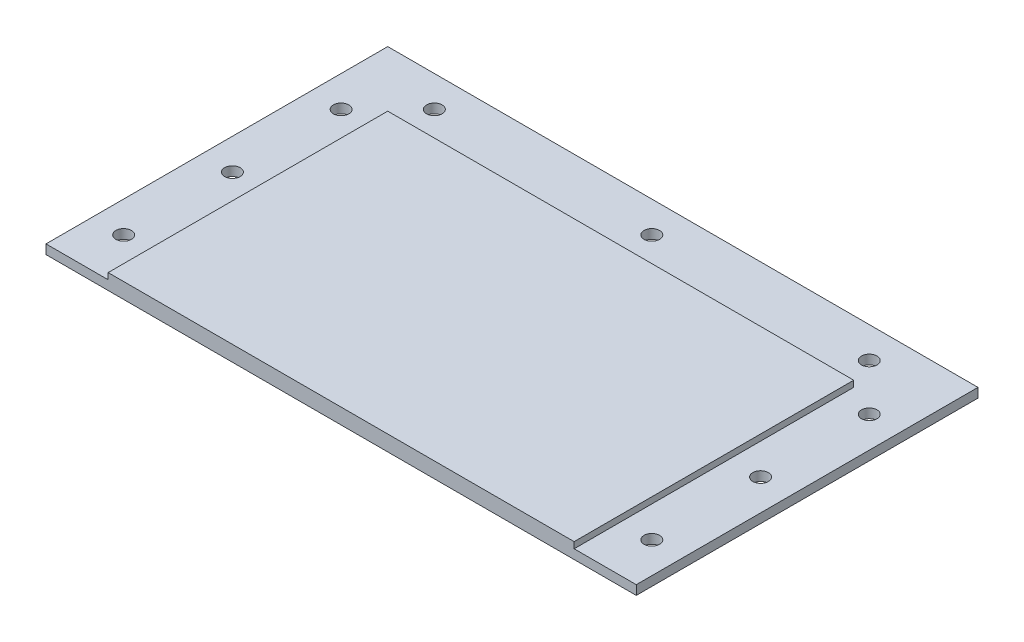
from build123d import *

# Parameters (mm, degrees)
CROQUIS1_W              = 150
CROQUIS1_H              = 90
SALIENTE_EXTRUIR1_DEPTH = 5
SALIENTE_EXTRUIR2_DEPTH = 3
CROQUIS2_R              = 2.5
CORTAR_EXTRUIR1_DEPTH   = 10


with BuildPart() as part:
    # Croquis1 → Saliente-Extruir1 (new body)
    with BuildSketch(Plane(origin=(0, 0, 0), x_dir=(1, 0, 0), z_dir=(0, 1, 0))):
        Rectangle(CROQUIS1_W, CROQUIS1_H)
    extrude(amount=SALIENTE_EXTRUIR1_DEPTH)

    # Croquis1_3 → Saliente-Extruir2 (add)
    with BuildSketch(Plane(origin=(0, 0, 0), x_dir=(1, 0, 0), z_dir=(0, 1, 0))):
        Polygon((-75, -45), (-75, 45), (75, 45), (75, -45), (95, -45), (95, 65), (-95, 65), (-95, -45), align=None)
    extrude(amount=SALIENTE_EXTRUIR2_DEPTH)

    # Croquis2 → Cortar-Extruir1 (cut)
    with BuildSketch(Plane.XZ):
        with Locations((85, 30)):
            Circle(CROQUIS2_R)
        with Locations((70, -55)):
            Circle(CROQUIS2_R)
        with Locations((-85, -40)):
            Circle(CROQUIS2_R)
        with Locations((-85, -5)):
            Circle(CROQUIS2_R)
        with Locations((-85, 30)):
            Circle(CROQUIS2_R)
        with Locations((0, -55)):
            Circle(CROQUIS2_R)
        with Locations((-70, -55)):
            Circle(CROQUIS2_R)
        with Locations((85, -5)):
            Circle(CROQUIS2_R)
        with Locations((85, -40)):
            Circle(CROQUIS2_R)
    extrude(amount=-CORTAR_EXTRUIR1_DEPTH, mode=Mode.SUBTRACT)


solid = part.part
